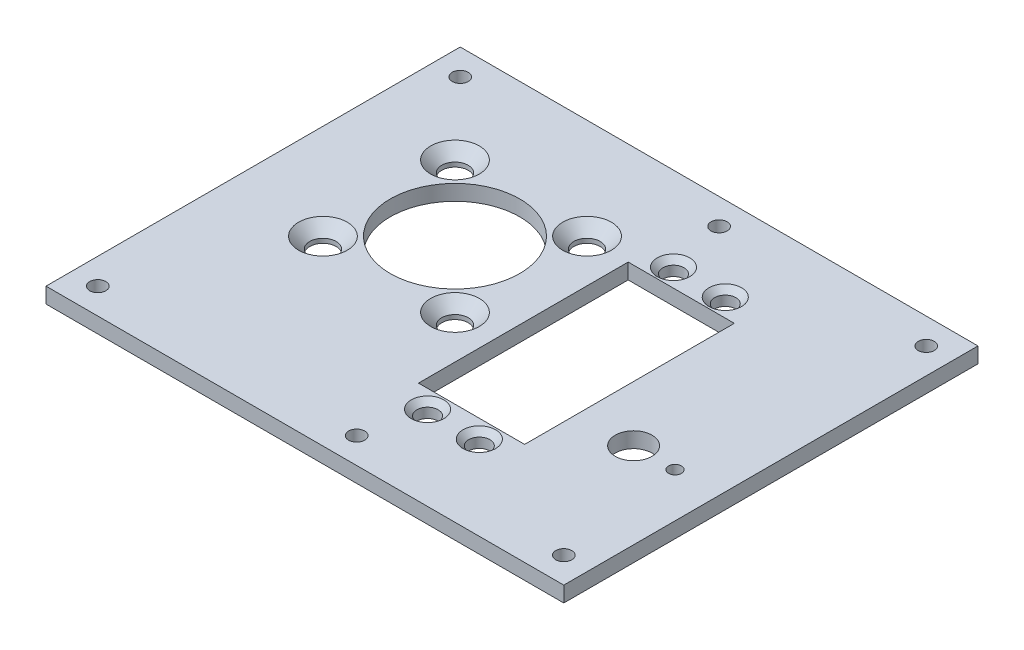
from build123d import *

# Parameters (mm, degrees)
SZKIC1_W                                     = 100
SZKIC1_H                                     = 80
SZKIC1_R                                     = 12.5
SZKIC1_R_2                                   = 2.55
SZKIC1_R_3                                   = 2.05
SZKIC1_R_4                                   = 3.55
SZKIC1_R_5                                   = 1.55
SZKIC1_R_6                                   = 1.25
SZKIC1_W_2                                   = 20.5
SZKIC1_H_2                                   = 40.5
DODANIE_WYCI_GNI_CIE1_DEPTH                  = 3
CSK_FOR_M4_COUNTERSUNK_FLAT_HEAD_SCR_2_COUNT = 2
CSK_FOR_M4_COUNTERSUNK_FLAT_HEAD_SCR_2_PITCH = 25.5
CSK_FOR_M4_COUNTERSUNK_FLAT_HEAD_SCR_3_COUNT = 2
CSK_FOR_M4_COUNTERSUNK_FLAT_HEAD_SCR_3_PITCH = 36.062445841
CSK_FOR_M4_COUNTERSUNK_FLAT_HEAD_SCR_4_COUNT = 2
CSK_FOR_M4_COUNTERSUNK_FLAT_HEAD_SCR_4_PITCH = 25.5
CSK_FOR_M3_COUNTERSUNK_FLAT_HEAD_SCR_2_COUNT = 2
CSK_FOR_M3_COUNTERSUNK_FLAT_HEAD_SCR_2_PITCH = 10
CSK_FOR_M3_COUNTERSUNK_FLAT_HEAD_SCR_3_COUNT = 2
CSK_FOR_M3_COUNTERSUNK_FLAT_HEAD_SCR_3_PITCH = 47.5
CSK_FOR_M3_COUNTERSUNK_FLAT_HEAD_SCR_4_COUNT = 2
CSK_FOR_M3_COUNTERSUNK_FLAT_HEAD_SCR_4_PITCH = 48.541219597


with BuildPart() as part:
    # Szkic1 → Dodanie-wyciągnięcie1 (new body)
    with BuildSketch(Plane(origin=(0, 0, 0), x_dir=(1, 0, 0), z_dir=(0, 1, 0))):
        with Locations((11.336719097, -8.838965942)):
            Rectangle(SZKIC1_W, SZKIC1_H)
        with Locations((-7.518770099, -0.993104788)):
            Circle(SZKIC1_R, mode=Mode.SUBTRACT)
        with Locations((-20.268770099, 11.756895212)):
            Circle(SZKIC1_R_2, mode=Mode.SUBTRACT)
        with Locations((5.231229901, 11.756895212)):
            Circle(SZKIC1_R_2, mode=Mode.SUBTRACT)
        with Locations((5.231229901, -13.743104788)):
            Circle(SZKIC1_R_2, mode=Mode.SUBTRACT)
        with Locations((-20.268770099, -13.743104788)):
            Circle(SZKIC1_R_2, mode=Mode.SUBTRACT)
        with Locations((18.775116298, 14.911034058)):
            Circle(SZKIC1_R_3, mode=Mode.SUBTRACT)
        with Locations((28.775116298, 14.911034058)):
            Circle(SZKIC1_R_3, mode=Mode.SUBTRACT)
        with Locations((18.775116298, -32.588965942)):
            Circle(SZKIC1_R_3, mode=Mode.SUBTRACT)
        with Locations((28.775116298, -32.588965942)):
            Circle(SZKIC1_R_3, mode=Mode.SUBTRACT)
        with Locations((44.775116298, -18.788965942)):
            Circle(SZKIC1_R_4, mode=Mode.SUBTRACT)
        with Locations((-33.663280903, 26.161034058)):
            Circle(SZKIC1_R_5, mode=Mode.SUBTRACT)
        with Locations((56.336719097, 26.161034058)):
            Circle(SZKIC1_R_5, mode=Mode.SUBTRACT)
        with Locations((56.336719097, -43.838965942)):
            Circle(SZKIC1_R_5, mode=Mode.SUBTRACT)
        with Locations((-33.663280903, -43.838965942)):
            Circle(SZKIC1_R_5, mode=Mode.SUBTRACT)
        with Locations((16.336719097, 26.161034058)):
            Circle(SZKIC1_R_5, mode=Mode.SUBTRACT)
        with Locations((16.336719097, -43.838965942)):
            Circle(SZKIC1_R_5, mode=Mode.SUBTRACT)
        with Locations((52.775116298, -18.788965942)):
            Circle(SZKIC1_R_6, mode=Mode.SUBTRACT)
        with Locations((23.775116298, -8.838965942)):
            Rectangle(SZKIC1_W_2, SZKIC1_H_2, mode=Mode.SUBTRACT)
    extrude(amount=DODANIE_WYCI_GNI_CIE1_DEPTH)

    # Sketch4 → CSK for M4 Countersunk Flat Head Screw1 (revolve, cut)
    with BuildSketch(Plane(origin=(-20.268770099, 3, 13.743104788), x_dir=(0, 0, 1), z_dir=(1, 0, 0))):
        Polygon((0, 0), (0, 3), (2.25, 3), (2.25, 2.45), (4.7, 0), align=None)
    csk_for_m4_countersunk_flat_head_screw1 = revolve(axis=Axis((-20.268770099, 9.35, 13.743104788), (0, -1, 0)), mode=Mode.SUBTRACT)

    # CSK for M4 Countersunk Flat Head Scr 2: CSK for M4 Countersunk Flat Head Screw1 ×2
    with Locations(*[(i * CSK_FOR_M4_COUNTERSUNK_FLAT_HEAD_SCR_2_PITCH, 0, 0) for i in range(1, CSK_FOR_M4_COUNTERSUNK_FLAT_HEAD_SCR_2_COUNT)]):
        add(csk_for_m4_countersunk_flat_head_screw1, mode=Mode.SUBTRACT)

    # CSK for M4 Countersunk Flat Head Scr 3: CSK for M4 Countersunk Flat Head Screw1 ×2
    with Locations(*[Vector(0.707106781, 0, -0.707106781) * (i * CSK_FOR_M4_COUNTERSUNK_FLAT_HEAD_SCR_3_PITCH) for i in range(1, CSK_FOR_M4_COUNTERSUNK_FLAT_HEAD_SCR_3_COUNT)]):
        add(csk_for_m4_countersunk_flat_head_screw1, mode=Mode.SUBTRACT)

    # CSK for M4 Countersunk Flat Head Scr 4: CSK for M4 Countersunk Flat Head Screw1 ×2
    with Locations(*[(0, 0, -i * CSK_FOR_M4_COUNTERSUNK_FLAT_HEAD_SCR_4_PITCH) for i in range(1, CSK_FOR_M4_COUNTERSUNK_FLAT_HEAD_SCR_4_COUNT)]):
        add(csk_for_m4_countersunk_flat_head_screw1, mode=Mode.SUBTRACT)

    # Sketch6 → CSK for M3 Countersunk Flat Head Screw1 (revolve, cut)
    with BuildSketch(Plane(origin=(18.775116298, 3, -14.911034058), x_dir=(0, 0, 1), z_dir=(1, 0, 0))):
        Polygon((0, 0), (0, 3), (1.7, 3), (1.7, 1.45), (3.15, 0), align=None)
    csk_for_m3_countersunk_flat_head_screw1 = revolve(axis=Axis((18.775116298, 9.35, -14.911034058), (0, -1, 0)), mode=Mode.SUBTRACT)

    # CSK for M3 Countersunk Flat Head Scr 2: CSK for M3 Countersunk Flat Head Screw1 ×2
    with Locations(*[(i * CSK_FOR_M3_COUNTERSUNK_FLAT_HEAD_SCR_2_PITCH, 0, 0) for i in range(1, CSK_FOR_M3_COUNTERSUNK_FLAT_HEAD_SCR_2_COUNT)]):
        add(csk_for_m3_countersunk_flat_head_screw1, mode=Mode.SUBTRACT)

    # CSK for M3 Countersunk Flat Head Scr 3: CSK for M3 Countersunk Flat Head Screw1 ×2
    with Locations(*[(0, 0, i * CSK_FOR_M3_COUNTERSUNK_FLAT_HEAD_SCR_3_PITCH) for i in range(1, CSK_FOR_M3_COUNTERSUNK_FLAT_HEAD_SCR_3_COUNT)]):
        add(csk_for_m3_countersunk_flat_head_screw1, mode=Mode.SUBTRACT)

    # CSK for M3 Countersunk Flat Head Scr 4: CSK for M3 Countersunk Flat Head Screw1 ×2
    with Locations(*[Vector(0.206010481, 0, 0.978549785) * (i * CSK_FOR_M3_COUNTERSUNK_FLAT_HEAD_SCR_4_PITCH) for i in range(1, CSK_FOR_M3_COUNTERSUNK_FLAT_HEAD_SCR_4_COUNT)]):
        add(csk_for_m3_countersunk_flat_head_screw1, mode=Mode.SUBTRACT)


solid = part.part
